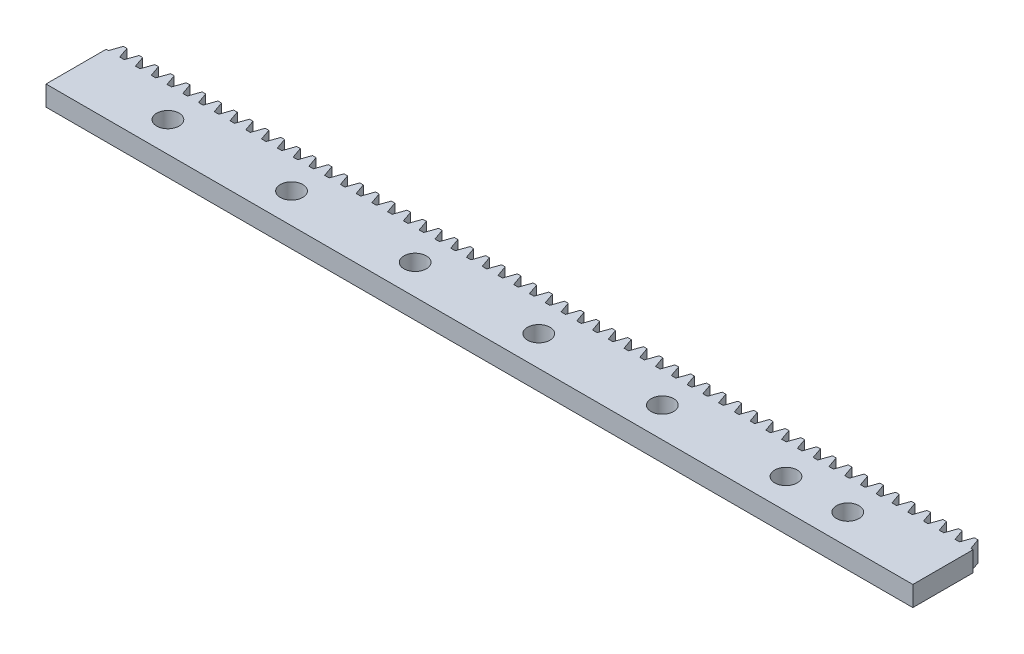
from build123d import *

# Parameters (mm, degrees)
SKETCH1_R           = 1.778
BOSS_EXTRUDE1_DEPTH = 3.175


with BuildPart() as part:
    # Sketch1 → Boss-Extrude1 (new body)
    with BuildSketch(Plane.XZ):
        Polygon((14.606788287, -4.7625), (15.316881609, -4.7625), (15.926300331, -6.511544), (16.491008723, -6.511544), (17.100427445, -4.7625), (17.810520767, -4.7625), (18.419939489, -6.511544), (18.984647881, -6.511544), (19.594066603, -4.7625), (19.949113264, -4.7625), (19.949113264, 4.7625), (-117.203516291, 4.7625), (-117.203516291, -4.7625), (-116.845993765, -4.7625), (-116.236575043, -6.511544), (-115.671866651, -6.511544), (-115.062447929, -4.7625), (-114.352354607, -4.7625), (-113.742935885, -6.511544), (-113.178227493, -6.511544), (-112.568808771, -4.7625), (-111.858715449, -4.7625), (-111.249296727, -6.511544), (-110.684588335, -6.511544), (-110.075169613, -4.7625), (-109.365076291, -4.7625), (-108.755657569, -6.511544), (-108.190949177, -6.511544), (-107.581530455, -4.7625), (-106.871437133, -4.7625), (-106.262018411, -6.511544), (-105.697310019, -6.511544), (-105.087891297, -4.7625), (-104.377797975, -4.7625), (-103.768379253, -6.511544), (-103.203670861, -6.511544), (-102.594252139, -4.7625), (-101.884158817, -4.7625), (-101.274740095, -6.511544), (-100.710031703, -6.511544), (-100.100612981, -4.7625), (-99.390519659, -4.7625), (-98.781100937, -6.511544), (-98.216392545, -6.511544), (-97.606973823, -4.7625), (-96.896880501, -4.7625), (-96.287461779, -6.511544), (-95.722753387, -6.511544), (-95.113334665, -4.7625), (-94.403241343, -4.7625), (-93.793822621, -6.511544), (-93.229114229, -6.511544), (-92.619695507, -4.7625), (-91.909602185, -4.7625), (-91.300183463, -6.511544), (-90.735475071, -6.511544), (-90.126056349, -4.7625), (-89.415963027, -4.7625), (-88.806544305, -6.511544), (-88.241835913, -6.511544), (-87.632417191, -4.7625), (-86.922323869, -4.7625), (-86.312905147, -6.511544), (-85.748196755, -6.511544), (-85.138778033, -4.7625), (-84.428684711, -4.7625), (-83.819265989, -6.511544), (-83.254557597, -6.511544), (-82.645138875, -4.7625), (-81.935045553, -4.7625), (-81.325626831, -6.511544), (-80.760918439, -6.511544), (-80.151499717, -4.7625), (-79.441406395, -4.7625), (-78.831987673, -6.511544), (-78.267279281, -6.511544), (-77.657860559, -4.7625), (-76.947767237, -4.7625), (-76.338348515, -6.511544), (-75.773640123, -6.511544), (-75.164221401, -4.7625), (-74.454128079, -4.7625), (-73.844709357, -6.511544), (-73.280000965, -6.511544), (-72.670582243, -4.7625), (-71.960488921, -4.7625), (-71.351070199, -6.511544), (-70.786361807, -6.511544), (-70.176943085, -4.7625), (-69.466849763, -4.7625), (-68.857431041, -6.511544), (-68.292722649, -6.511544), (-67.683303927, -4.7625), (-66.973210605, -4.7625), (-66.363791883, -6.511544), (-65.799083491, -6.511544), (-65.189664769, -4.7625), (-64.479571447, -4.7625), (-63.870152725, -6.511544), (-63.305444333, -6.511544), (-62.696025611, -4.7625), (-61.985932289, -4.7625), (-61.376513567, -6.511544), (-60.811805175, -6.511544), (-60.202386453, -4.7625), (-59.492293131, -4.7625), (-58.882874409, -6.511544), (-58.318166017, -6.511544), (-57.708747295, -4.7625), (-56.998653973, -4.7625), (-56.389235251, -6.511544), (-55.824526859, -6.511544), (-55.215108137, -4.7625), (-54.505014815, -4.7625), (-53.895596093, -6.511544), (-53.330887701, -6.511544), (-52.721468979, -4.7625), (-52.011375657, -4.7625), (-51.401956935, -6.511544), (-50.837248543, -6.511544), (-50.227829821, -4.7625), (-49.517736499, -4.7625), (-48.908317777, -6.511544), (-48.343609385, -6.511544), (-47.734190663, -4.7625), (-47.024097341, -4.7625), (-46.414678619, -6.511544), (-45.849970227, -6.511544), (-45.240551505, -4.7625), (-44.530458183, -4.7625), (-43.921039461, -6.511544), (-43.356331069, -6.511544), (-42.746912347, -4.7625), (-42.036819025, -4.7625), (-41.427400303, -6.511544), (-40.862691911, -6.511544), (-40.253273189, -4.7625), (-39.543179867, -4.7625), (-38.933761145, -6.511544), (-38.369052753, -6.511544), (-37.759634031, -4.7625), (-37.049540709, -4.7625), (-36.440121987, -6.511544), (-35.875413595, -6.511544), (-35.265994873, -4.7625), (-34.555901551, -4.7625), (-33.946482829, -6.511544), (-33.381774437, -6.511544), (-32.772355715, -4.7625), (-32.062262393, -4.7625), (-31.452843671, -6.511544), (-30.888135279, -6.511544), (-30.278716557, -4.7625), (-29.568623235, -4.7625), (-28.959204513, -6.511544), (-28.394496121, -6.511544), (-27.785077399, -4.7625), (-27.074984077, -4.7625), (-26.465565355, -6.511544), (-25.900856963, -6.511544), (-25.291438241, -4.7625), (-24.581344919, -4.7625), (-23.971926197, -6.511544), (-23.407217805, -6.511544), (-22.797799083, -4.7625), (-22.087705761, -4.7625), (-21.478287039, -6.511544), (-20.913578647, -6.511544), (-20.304159925, -4.7625), (-19.594066603, -4.7625), (-18.984647881, -6.511544), (-18.419939489, -6.511544), (-17.810520767, -4.7625), (-17.100427445, -4.7625), (-16.491008723, -6.511544), (-15.926300331, -6.511544), (-15.316881609, -4.7625), (-14.606788287, -4.7625), (-13.997369565, -6.511544), (-13.432661173, -6.511544), (-12.823242451, -4.7625), (-12.113149129, -4.7625), (-11.503730407, -6.511544), (-10.939022015, -6.511544), (-10.329603293, -4.7625), (-9.619509971, -4.7625), (-9.010091249, -6.511544), (-8.445382857, -6.511544), (-7.835964135, -4.7625), (-7.125870813, -4.7625), (-6.516452091, -6.511544), (-5.951743699, -6.511544), (-5.342324977, -4.7625), (-4.632231655, -4.7625), (-4.022812933, -6.511544), (-3.458104541, -6.511544), (-2.848685819, -4.7625), (-2.138592497, -4.7625), (-1.529173775, -6.511544), (-0.964465383, -6.511544), (-0.355046661, -4.7625), (0.355046661, -4.7625), (0.964465383, -6.511544), (1.529173775, -6.511544), (2.138592497, -4.7625), (2.848685819, -4.7625), (3.458104541, -6.511544), (4.022812933, -6.511544), (4.632231655, -4.7625), (5.342324977, -4.7625), (5.951743699, -6.511544), (6.516452091, -6.511544), (7.125870813, -4.7625), (7.835964135, -4.7625), (8.445382857, -6.511544), (9.010091249, -6.511544), (9.619509971, -4.7625), (10.329603293, -4.7625), (10.939022015, -6.511544), (11.503730407, -6.511544), (12.113149129, -4.7625), (12.823242451, -4.7625), (13.432661173, -6.511544), (13.997369565, -6.511544), align=None)
        with Locations((4.88696, 0)):
            Circle(SKETCH1_R, mode=Mode.SUBTRACT)
        with Locations((-102.67696, 0)):
            Circle(SKETCH1_R, mode=Mode.SUBTRACT)
        with Locations((-83.11896, 0)):
            Circle(SKETCH1_R, mode=Mode.SUBTRACT)
        with Locations((-63.56096, 0)):
            Circle(SKETCH1_R, mode=Mode.SUBTRACT)
        with Locations((-44.00296, 0)):
            Circle(SKETCH1_R, mode=Mode.SUBTRACT)
        with Locations((-24.44496, 0)):
            Circle(SKETCH1_R, mode=Mode.SUBTRACT)
        with Locations((-4.88696, 0)):
            Circle(SKETCH1_R, mode=Mode.SUBTRACT)
    extrude(amount=-BOSS_EXTRUDE1_DEPTH)


solid = part.part
